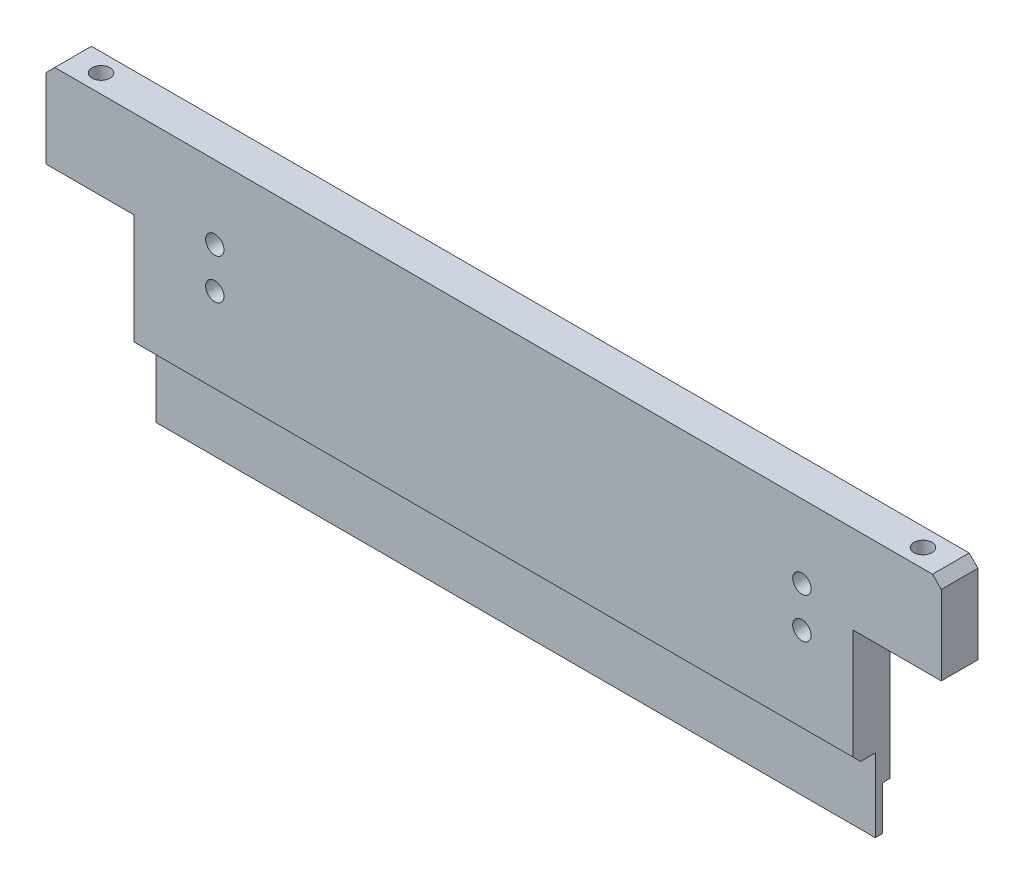
from build123d import *

# Parameters (mm, degrees)
BOSS_EXTRUDE1_DEPTH = 5
SKETCH2_W           = 12
SKETCH2_H           = 26
CUT_EXTRUDE1_DEPTH  = 6
SKETCH3_R           = 1.25
CUT_EXTRUDE2_DEPTH  = 6
SKETCH4_R           = 1.23
CUT_EXTRUDE3_DEPTH  = 13
SKETCH5_W           = 98
SKETCH5_H           = 10
CUT_EXTRUDE4_DEPTH  = 3
SKETCH6_W           = 98
SKETCH6_H           = 6
CUT_EXTRUDE5_DEPTH  = 1
CHAMFER1_SIZE       = 1


with BuildPart() as part:
    # Sketch1 → Boss-Extrude1 (new body)
    with BuildSketch(Plane.XY):
        Polygon((-61, 17.8), (-59.8, 19), (59.8, 19), (61, 17.8), (61, -19), (-61, -19), align=None)
    extrude(amount=BOSS_EXTRUDE1_DEPTH)

    # Sketch2 → Cut-Extrude1 (cut, through all)
    with BuildSketch(Plane.XY.offset(5)):
        with Locations((55, -6)):
            Rectangle(SKETCH2_W, SKETCH2_H)
    cut_extrude1 = extrude(amount=-CUT_EXTRUDE1_DEPTH, mode=Mode.SUBTRACT)

    # Sketch3 → Cut-Extrude2 (cut, through all)
    with BuildSketch(Plane.XY.offset(5)):
        with Locations((42, 9)):
            Circle(SKETCH3_R)
        with Locations((42, 3.5)):
            Circle(SKETCH3_R)
        with Locations((-38, 9)):
            Circle(SKETCH3_R)
        with Locations((-38, 3.5)):
            Circle(SKETCH3_R)
    extrude(amount=-CUT_EXTRUDE2_DEPTH, mode=Mode.SUBTRACT)

    # Sketch4 → Cut-Extrude3 (cut, through all)
    with BuildSketch(Plane.XZ.offset(-7)):
        with Locations((56, 2.5)):
            Circle(SKETCH4_R)
    cut_extrude3 = extrude(amount=-CUT_EXTRUDE3_DEPTH, mode=Mode.SUBTRACT)

    # Mirror1: Cut-Extrude1, Cut-Extrude3 across plane
    add(cut_extrude1.mirror(Plane(origin=(0, 0, 0), x_dir=(0, 0, 1), z_dir=(1, 0, 0))), mode=Mode.SUBTRACT)
    add(cut_extrude3.mirror(Plane(origin=(0, 0, 0), x_dir=(0, 0, 1), z_dir=(1, 0, 0))), mode=Mode.SUBTRACT)

    # Sketch5 → Cut-Extrude4 (cut)
    with BuildSketch(Plane.XY.offset(5)):
        with Locations((0, -14)):
            Rectangle(SKETCH5_W, SKETCH5_H)
    extrude(amount=-CUT_EXTRUDE4_DEPTH, mode=Mode.SUBTRACT)

    # Sketch6 → Cut-Extrude5 (cut)
    with BuildSketch(Plane(origin=(0, 0, 0), x_dir=(-1, 0, 0), z_dir=(0, 0, -1))):
        with Locations((0, -16)):
            Rectangle(SKETCH6_W, SKETCH6_H)
    extrude(amount=-CUT_EXTRUDE5_DEPTH, mode=Mode.SUBTRACT)

    # Chamfer1
    chamfer1_edges = [part.edges().sort_by_distance(p)[0] for p in [
        (0, -9, 5),
    ]]
    chamfer(chamfer1_edges, length=CHAMFER1_SIZE)


solid = part.part
